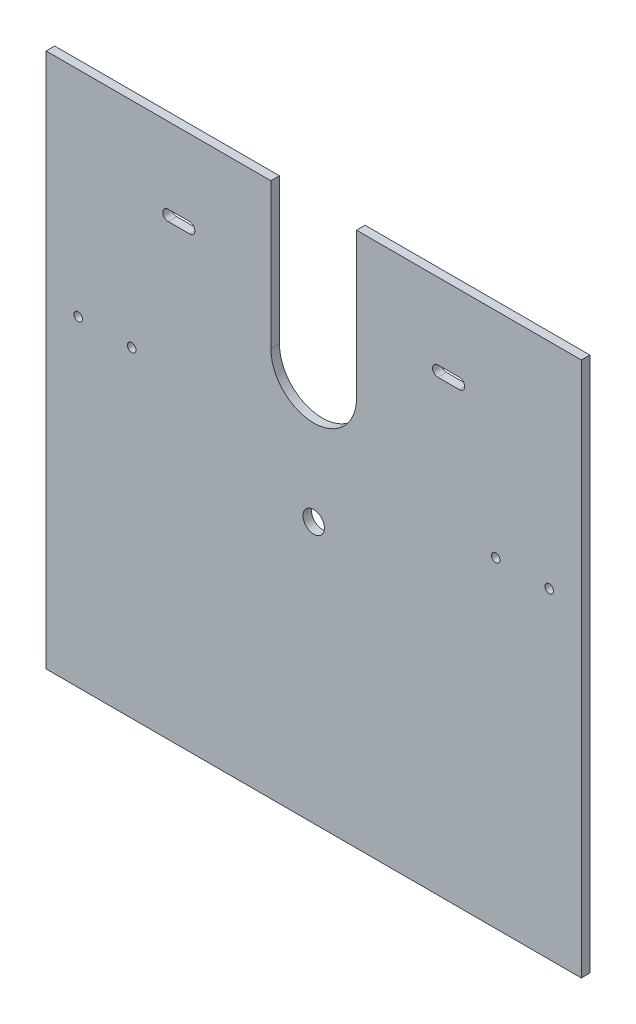
from build123d import *

# Parameters (mm, degrees)
SKETCH1_W           = 250
SKETCH1_H           = 200
BOSS_EXTRUDE1_DEPTH = 4
SKETCH2_R           = 2
CUT_EXTRUDE1_DEPTH  = 4
SKETCH3_R           = 5
CUT_EXTRUDE2_DEPTH  = 4
SKETCH8_W           = 250
SKETCH8_H           = 4
BOSS_EXTRUDE2_DEPTH = 50


with BuildPart() as part:
    # Sketch1 → Boss-Extrude1 (new body)
    with BuildSketch(Plane.XY):
        Rectangle(SKETCH1_W, SKETCH1_H)
    extrude(amount=BOSS_EXTRUDE1_DEPTH)

    # Sketch2 → Cut-Extrude1 (cut)
    with BuildSketch(Plane.XY.offset(4)):
        with Locations((-110, 0)):
            Circle(SKETCH2_R)
        with Locations((-85, 0)):
            Circle(SKETCH2_R)
        with Locations((110, 0)):
            Circle(SKETCH2_R)
        with Locations((85, 0)):
            Circle(SKETCH2_R)
    extrude(amount=-CUT_EXTRUDE1_DEPTH, mode=Mode.SUBTRACT)

    # Sketch3 → Cut-Extrude2 (cut)
    with BuildSketch(Plane.XY.offset(4)):
        with Locations((0, -28)):
            Circle(SKETCH3_R)
        with BuildLine():
            Line((20, 32), (20, 100))
            Line((20, 100), (-20, 100))
            Line((-20, 100), (-20, 32))
            ThreePointArc((-20, 32), (0, 12), (20, 32))
        make_face()
        with BuildLine():
            Line((-68, 64.5), (-58, 64.5))
            ThreePointArc((-58, 64.5), (-55.5, 62), (-58, 59.5))
            Line((-58, 59.5), (-68, 59.5))
            ThreePointArc((-68, 59.5), (-70.5, 62), (-68, 64.5))
        make_face()
        with BuildLine():
            Line((58, 59.5), (68, 59.5))
            ThreePointArc((68, 59.5), (70.5, 62), (68, 64.5))
            Line((68, 64.5), (58, 64.5))
            ThreePointArc((58, 64.5), (55.5, 62), (58, 59.5))
        make_face()
    extrude(amount=-CUT_EXTRUDE2_DEPTH, mode=Mode.SUBTRACT)

    # Sketch8 → Boss-Extrude2 (add)
    with BuildSketch(Plane.XZ.offset(100)):
        with Locations((0, 2)):
            Rectangle(SKETCH8_W, SKETCH8_H)
    extrude(amount=BOSS_EXTRUDE2_DEPTH)


solid = part.part
